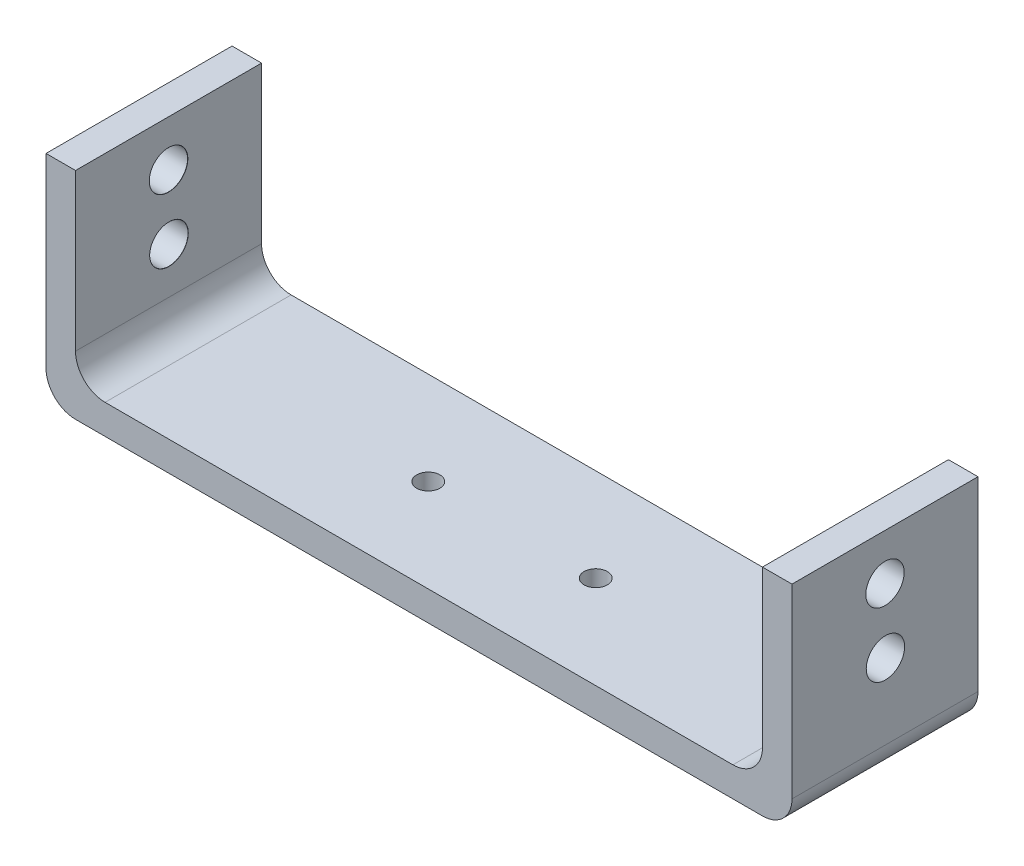
from build123d import *

# Parameters (mm, degrees)
SKETCH1_W                             = 154.05
SKETCH1_H                             = 40
BOSS_EXTRUDE1_DEPTH                   = 6.35
SKETCH2_W                             = 6.35
SKETCH2_H                             = 40
BOSS_EXTRUDE2_DEPTH                   = 40
FILLET1_R                             = 6.35
TAP_DRILL_FOR_M8_HELICOIL1_AT_2_COUNT = 2
TAP_DRILL_FOR_M8_HELICOIL1_AT_2_PITCH = 13.884315024
FILLET1_OF_MIRROR1_R                  = 6.35
SKETCH6_R                             = 2.5
CUT_EXTRUDE1_DEPTH                    = 40


with BuildPart() as part:
    # Sketch1 → Boss-Extrude1 (new body)
    with BuildSketch(Plane(origin=(0, 0, 0), x_dir=(1, 0, 0), z_dir=(0, 1, 0))):
        with Locations((-77.025, 20)):
            Rectangle(SKETCH1_W, SKETCH1_H)
    boss_extrude1 = extrude(amount=BOSS_EXTRUDE1_DEPTH)

    # Sketch2 → Boss-Extrude2 (add)
    with BuildSketch(Plane(origin=(0, 6.35, 0), x_dir=(1, 0, 0), z_dir=(0, 1, 0))):
        with Locations((-3.175, 20)):
            Rectangle(SKETCH2_W, SKETCH2_H)
    boss_extrude2 = extrude(amount=BOSS_EXTRUDE2_DEPTH)

    # Fillet1
    fillet1_edges = [part.edges().sort_by_distance(p)[0] for p in [
        (-6.35, 6.35, -20),
        (0, 0, -20),
    ]]
    fillet(fillet1_edges, radius=FILLET1_R)

    # Sketch5 → Tap Drill for M8 Helicoil1 (revolve, cut)
    with BuildSketch(Plane(origin=(-6.35, 36.467, -20), x_dir=(0, 0, 1), z_dir=(0, 1, 0))):
        Polygon((0, 0), (0, 6.35), (4.125, 6.35), (4.125, 0.025), (4.15, 0), align=None)
    tap_drill_for_m8_helicoil1 = revolve(axis=Axis((-12.7, 36.467, -20), (1, 0, 0)), mode=Mode.SUBTRACT)

    # Tap Drill for M8 Helicoil1 at 2: Tap Drill for M8 Helicoil1 ×2
    with Locations(*[Vector(0, -0.9999773107839142, -0.006736313336781501) * (i * TAP_DRILL_FOR_M8_HELICOIL1_AT_2_PITCH) for i in range(1, TAP_DRILL_FOR_M8_HELICOIL1_AT_2_COUNT)]):
        add(tap_drill_for_m8_helicoil1, mode=Mode.SUBTRACT)

    # Mirror1: Boss-Extrude1, Boss-Extrude2, Tap Drill for M8 Helicoil1 across plane
    add(boss_extrude1.mirror(Plane.ZY.offset(80.2)))
    add(boss_extrude2.mirror(Plane.ZY.offset(80.2)))
    add(tap_drill_for_m8_helicoil1.mirror(Plane.ZY.offset(80.2)), mode=Mode.SUBTRACT)

    # Mirror1 copy 1 sketch → Mirror1 copy 1 (revolve, cut)
    with BuildSketch(Plane(origin=(-154.05, 22.583, -20.093529096), x_dir=(0, 0, 1), z_dir=(0, 1, 0))):
        Polygon((0, 0), (0, -6.35), (4.125, -6.35), (4.125, -0.025), (4.15, 0), align=None)
    revolve(axis=Axis((-147.7, 22.583, -20.093529096), (1, 0, 0)), mode=Mode.SUBTRACT)

    # Fillet1 of Mirror1
    fillet1_of_mirror1_edges = [part.edges().sort_by_distance(p)[0] for p in [
        (-154.05, 6.35, -20),
        (-160.4, 0, -20),
    ]]
    fillet(fillet1_of_mirror1_edges, radius=FILLET1_OF_MIRROR1_R)

    # Sketch6 → Cut-Extrude1 (cut)
    with BuildSketch(Plane(origin=(0, 6.35, 0), x_dir=(1, 0, 0), z_dir=(0, 1, 0))):
        with Locations(Location((-98.2, 20, 0), (0, 0, 270))):
            Circle(SKETCH6_R)
        with Locations(Location((-62.2, 20, 0), (0, 0, 270))):
            Circle(SKETCH6_R)
    extrude(amount=-CUT_EXTRUDE1_DEPTH, mode=Mode.SUBTRACT)


solid = part.part
